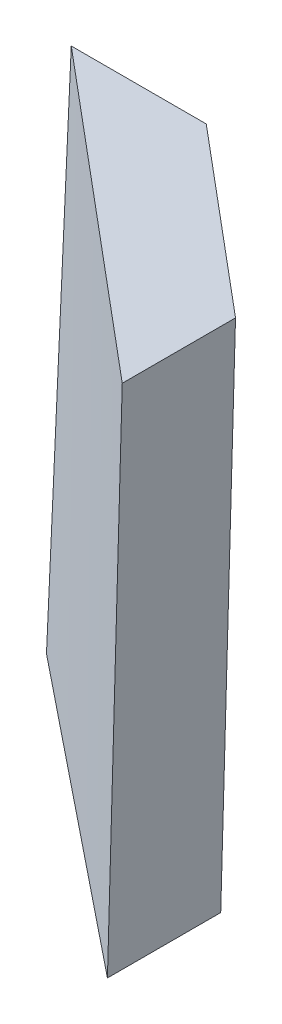
from build123d import *


with BuildPart() as part:
    # Croquis1 → Recubrir1 section 0
    with BuildSketch(Plane(origin=(0, 0, 0), x_dir=(1, 0, 0), z_dir=(0, 1, 0))):
        Polygon((0, 0), (19.45, 0), (44.855290258, -19.751547456), (44.855290258, -36.071547456), align=None)
    # Croquis2 → Recubrir1 section 1
    with BuildSketch(Plane(origin=(0, 75, 0), x_dir=(1, 0, 0), z_dir=(0, 1, 0))):
        Polygon((0.95, 2.62), (20.4, 2.62), (46.706117884, -19.468699868), (46.706117884, -35.78892183), align=None)
    loft()


solid = part.part
